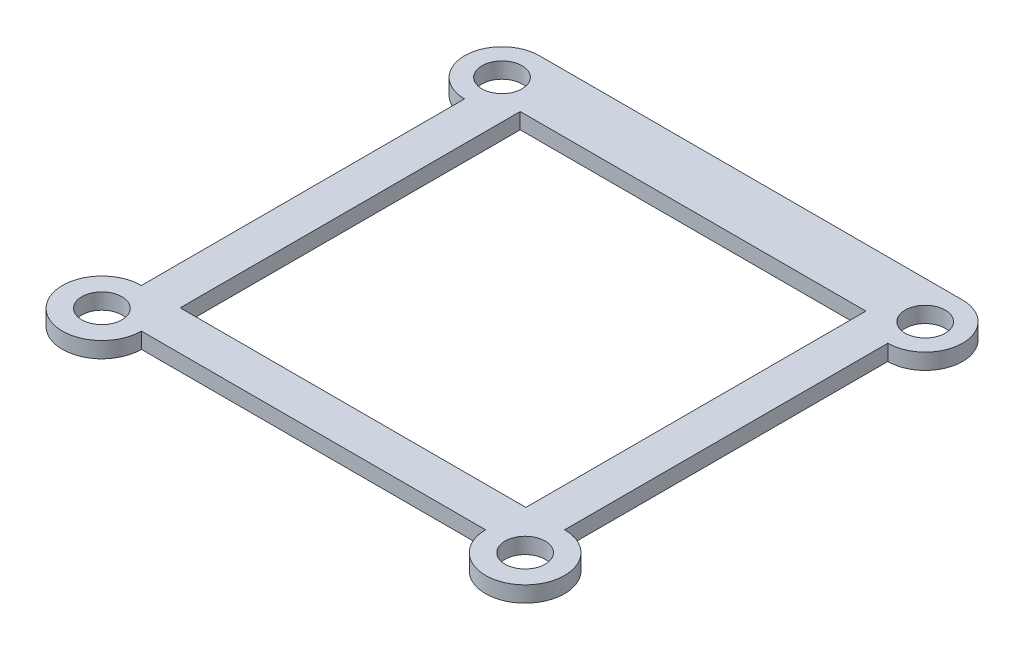
from build123d import *

# Parameters (mm, degrees)
SKETCH2_R           = 1.770040435
SKETCH2_W           = 30.5
SKETCH2_H           = 30
BOSS_EXTRUDE1_DEPTH = 1.4


with BuildPart() as part:
    # Sketch2 → Boss-Extrude1 (new body)
    with BuildSketch(Plane(origin=(0, 0, 0), x_dir=(1, 0, 0), z_dir=(0, 1, 0))):
        with BuildLine():
            Line((-8.84, 51.681103494), (28.5, 51.681103494))
            ThreePointArc((28.5, 51.681103494), (31.8, 48.381103494), (28.5, 45.081103494))
            Line((28.5, 45.081103494), (28.5, 16.569015353))
            ThreePointArc((28.5, 16.569015353), (30.966326128, 10.614777366), (25.012088141, 13.081103494))
            Line((25.012088141, 13.081103494), (-5.352088141, 13.081103494))
            ThreePointArc((-5.352088141, 13.081103494), (-11.306326128, 10.614777366), (-8.84, 16.569015353))
            Line((-8.84, 16.569015353), (-8.84, 45.081103494))
            ThreePointArc((-8.84, 45.081103494), (-12.14, 48.381103494), (-8.84, 51.681103494))
        make_face()
        with Locations((-8.84, 48.381103494)):
            Circle(SKETCH2_R, mode=Mode.SUBTRACT)
        with Locations((28.5, 48.381103494)):
            Circle(SKETCH2_R, mode=Mode.SUBTRACT)
        with Locations((-8.84, 13.081103494)):
            Circle(SKETCH2_R, mode=Mode.SUBTRACT)
        with Locations((28.5, 13.081103494)):
            Circle(SKETCH2_R, mode=Mode.SUBTRACT)
        with Locations((9.83, 31.569015353)):
            Rectangle(SKETCH2_W, SKETCH2_H, mode=Mode.SUBTRACT)
    extrude(amount=BOSS_EXTRUDE1_DEPTH)


solid = part.part
